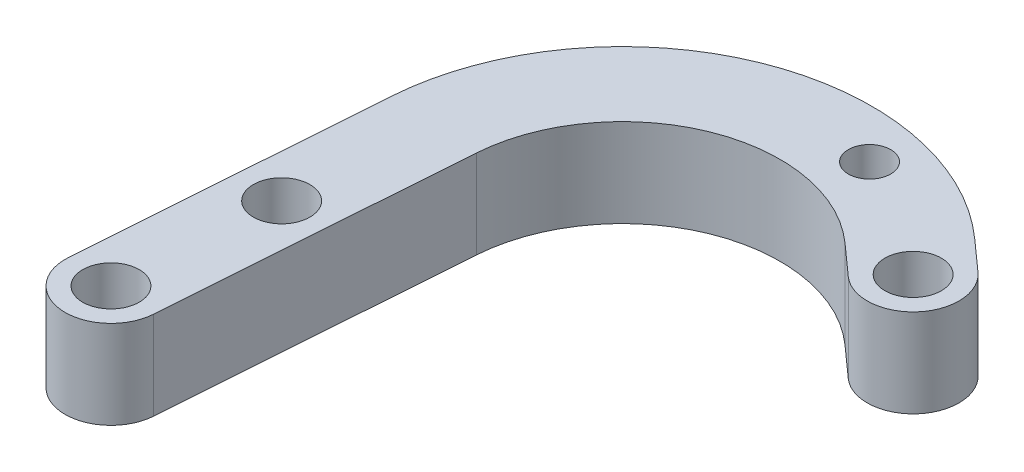
from build123d import *

# Parameters (mm, degrees)
SZKIC1_R                    = 8
DODANIE_WYCI_GNI_CIE1_DEPTH = 25
SZKIC2_R                    = 6
WYTNIJ_WYCI_GNI_CIE1_DEPTH  = 25
SZKIC3_R                    = 8
WYTNIJ_WYCI_GNI_CIE2_DEPTH  = 2000


with BuildPart() as part:
    # Szkic1 → Dodanie-wyciągnięcie1 (new body)
    with BuildSketch(Plane(origin=(0, 0, 0), x_dir=(1, 0, 0), z_dir=(0, 1, 0))):
        with BuildLine():
            Line((-145.921678768, -1.827473833), (-139.75350446, 83.413416114))
            ThreePointArc((-139.75350446, 83.413416114), (-95.818169931, 143.778859358), (-22.261154385, 130.985664988))
            Line((-22.261154385, 130.985664988), (-13.598892288, 123.247376031))
            ThreePointArc((-13.598892288, 123.247376031), (-12.564771829, 104.891706747), (-30.920441114, 103.857586288))
            Line((-30.920441114, 103.857586288), (-39.58270321, 111.595875245))
            ThreePointArc((-39.58270321, 111.595875245), (-86.060369899, 119.679371012), (-113.821309069, 81.536918796))
            Line((-113.821309069, 81.536918796), (-119.989483377, -3.703971151))
            ThreePointArc((-119.989483377, -3.703971151), (-133.893829731, -15.731820187), (-145.921678768, -1.827473833))
        make_face()
        with Locations((-132.955581072, -2.765722492)):
            Circle(SZKIC1_R, mode=Mode.SUBTRACT)
        with Locations((-22.259666701, 113.552481159)):
            Circle(SZKIC1_R, mode=Mode.SUBTRACT)
    extrude(amount=DODANIE_WYCI_GNI_CIE1_DEPTH)

    # Szkic2 → Wytnij-wyciągnięcie1 (cut)
    with BuildSketch(Plane(origin=(0, 25, 0), x_dir=(1, 0, 0), z_dir=(0, 1, 0))):
        with Locations((-56.034895704, 134.982224644)):
            Circle(SZKIC2_R)
    extrude(amount=-WYTNIJ_WYCI_GNI_CIE1_DEPTH, mode=Mode.SUBTRACT)

    # Szkic3 → Wytnij-wyciągnięcie2 (cut)
    with BuildSketch(Plane(origin=(0, 25, 0), x_dir=(1, 0, 0), z_dir=(0, 1, 0))):
        with Locations((-129.654921114, 42.234277508)):
            Circle(SZKIC3_R)
    extrude(amount=-WYTNIJ_WYCI_GNI_CIE2_DEPTH, mode=Mode.SUBTRACT)


solid = part.part
